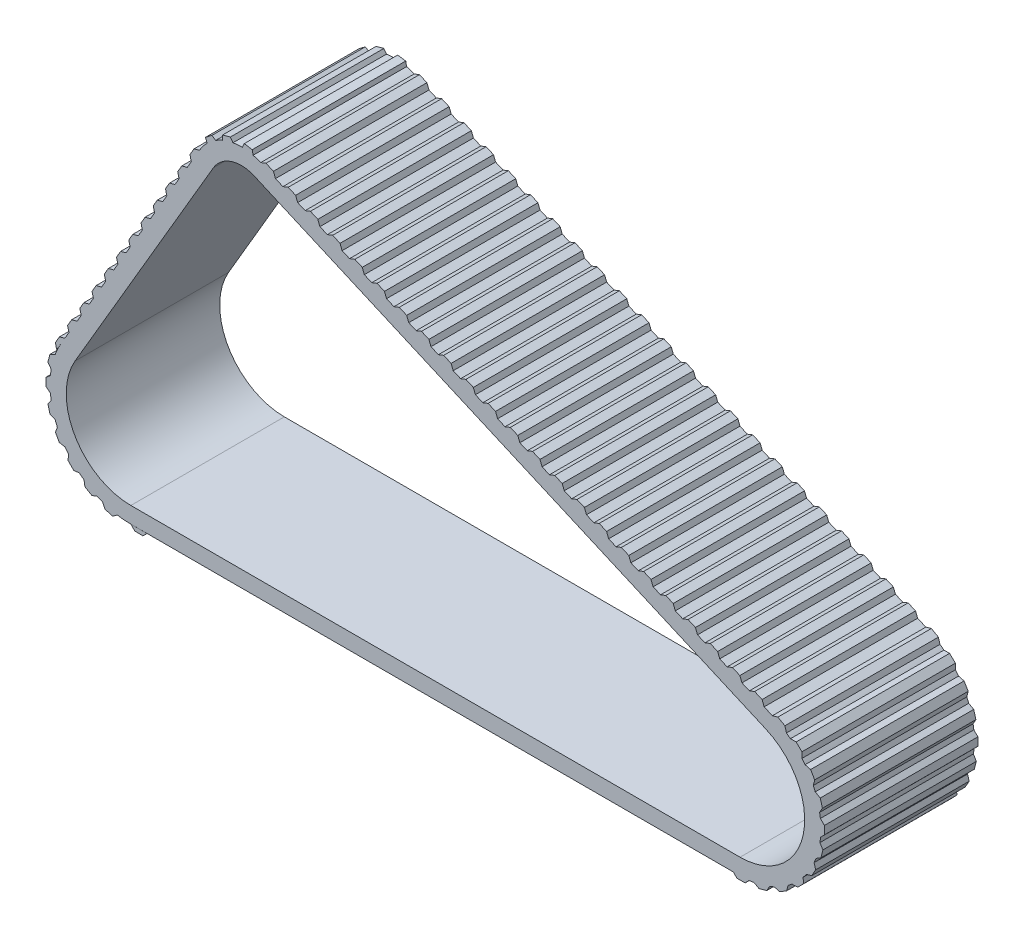
from build123d import *

# Parameters (mm, degrees)
EXTRUIR1_DEPTH         = 19
VACIADO1_T             = -2
CORTAR_EXTRUIR1_DEPTH  = 20
EXTRUIR2_DEPTH         = 19
MATRIZL1_COUNT         = 12
MATRIZL1_PITCH         = 3
EXTRUIR3_DEPTH         = 19
MATRIZL2_COUNT         = 23
MATRIZL2_PITCH         = 3
EXTRUIR4_DEPTH         = 19
MATRIZC2_COUNT         = 2
MATRIZC2_ANGLE         = 22
MATRIZC3_COUNT         = 2
MATRIZC3_ANGLE         = 24
EXTRUIR5_DEPTH         = 19
MATRIZC4_COUNT         = 11
MATRIZC4_ANGLE         = 150
EXTRUIR6_DEPTH         = 19
EXTRUIR7_DEPTH         = 19
MATRIZC5_COUNT         = 4
MATRIZC5_ANGLE         = 45
MATRIZC6_COPY_1_DEPTH  = 19
MATRIZC6_COPY_2_DEPTH  = 19
MATRIZC6_COPY_3_DEPTH  = 19
MATRIZC6_COPY_4_DEPTH  = 19
MATRIZC6_COPY_5_DEPTH  = 19
MATRIZC6_COPY_6_DEPTH  = 19
MATRIZC6_COPY_7_DEPTH  = 19
MATRIZC6_COPY_8_DEPTH  = 19
MATRIZC6_COPY_9_DEPTH  = 19
MATRIZC6_COPY_10_DEPTH = 19
MATRIZC6_COPY_11_DEPTH = 19
MATRIZC6_COPY_12_DEPTH = 19


with BuildPart() as part:
    # Croquis1 → Extruir1 (new body)
    with BuildSketch(Plane.XY):
        with BuildLine():
            Line((8.495183222, 34.324994884), (-8.631456282, 5.049550719))
            ThreePointArc((-8.631456282, 5.049550719), (-8.674546305, -4.975162953), (0, -10))
            Line((0, -10), (75.418767938, -10))
            ThreePointArc((75.418767938, -10), (85.208057182, -2.042012754), (79.416738635, 9.166036783))
            Line((79.416738635, 9.166036783), (16.072839409, 36.794886522))
            ThreePointArc((16.072839409, 36.794886522), (11.814670491, 36.999883795), (8.495183222, 34.324994884))
        make_face()
    extrude(amount=EXTRUIR1_DEPTH)

    # Vaciado1
    vaciado1_openings = [part.faces().sort_by_distance(p)[0] for p in [
        (33.687599882, 7.758573036, 19),
    ]]
    offset(amount=VACIADO1_T, openings=vaciado1_openings, kind=Kind.INTERSECTION)

    # Croquis2 → Cortar-Extruir1 (cut)
    with BuildSketch(Plane.XY.offset(2)):
        with BuildLine():
            Line((10.221474478, 33.31508474), (-6.905165025, 4.039640575))
            ThreePointArc((-6.905165025, 4.039640575), (-6.939637044, -3.980130362), (0, -8))
            Line((0, -8), (75.418767938, -8))
            ThreePointArc((75.418767938, -8), (83.250199333, -1.633610203), (78.617144496, 7.332829426))
            Line((78.617144496, 7.332829426), (15.27324527, 34.961679166))
            ThreePointArc((15.27324527, 34.961679166), (12.434465991, 35.098344014), (10.221474478, 33.31508474))
        make_face()
    extrude(amount=-CORTAR_EXTRUIR1_DEPTH, mode=Mode.SUBTRACT)

    # Croquis3 → Extruir2 (add)
    with BuildSketch(Plane.XY.offset(19)):
        Polygon((8.495183222, 34.324994884), (7.819852413, 34.140798524), (7.314897341, 33.277652895), (7.485273078, 32.598703627), align=None)
    extruir2 = extrude(amount=-EXTRUIR2_DEPTH)

    # MatrizL1: Extruir2 ×12
    with Locations(*[Vector(-0.504955072, -0.863145628, 0) * (i * MATRIZL1_PITCH) for i in range(1, MATRIZL1_COUNT)]):
        add(extruir2)

    # Croquis5 → Extruir3 (add)
    with BuildSketch(Plane.XY.offset(19)):
        Polygon((16.072839409, 36.794886522), (17.906046766, 35.995292383), (17.647643461, 36.653492757), (16.731039783, 37.053289827), align=None)
    extruir3 = extrude(amount=-EXTRUIR3_DEPTH)

    # MatrizL2: Extruir3 ×23
    with Locations(*[Vector(0.916603678, -0.39979707, 0) * (i * MATRIZL2_PITCH) for i in range(1, MATRIZL2_COUNT)]):
        add(extruir3)

    # Croquis8 → Extruir4 (add)
    with BuildSketch(Plane.XY.offset(19)):
        with BuildLine():
            Line((11.356671981, 37.399019639), (11.341082114, 36.823123733))
            ThreePointArc((11.341082114, 36.823123733), (11.980140179, 37.051187127), (12.640861941, 37.205637367))
            Line((12.640861941, 37.205637367), (12.321288909, 37.662675061))
            Line((12.321288909, 37.662675061), (11.356671981, 37.399019639))
        make_face()
    extruir4 = extrude(amount=-EXTRUIR4_DEPTH)

    # MatrizC2: Extruir4 ×2 about axis
    matrizc2_axis = Axis((13.674056991, 31.295264453, 0), (0, 0, 1))
    for i in range(1, MATRIZC2_COUNT):
        add(extruir4.rotate(matrizc2_axis, i * MATRIZC2_ANGLE / (MATRIZC2_COUNT - 1)))

    # MatrizC3: Extruir4 ×2 about axis
    matrizc3_axis = Axis((13.674056991, 31.295264453, 0), (0, 0, -1))
    for i in range(1, MATRIZC3_COUNT):
        add(extruir4.rotate(matrizc3_axis, i * MATRIZC3_ANGLE / (MATRIZC3_COUNT - 1)))

    # Croquis9 → Extruir5 (add)
    with BuildSketch(Plane.XY.offset(19)):
        Polygon((79.416738635, 9.166036783), (81.160797511, 8.187129923), (80.969509507, 8.867871357), (80.097480069, 9.357324787), align=None)
    extruir5 = extrude(amount=-EXTRUIR5_DEPTH)

    # MatrizC4: Extruir5 ×11 about axis
    matrizc4_axis = Axis((75.418767938, 0, 0), (0, 0, -1))
    for i in range(1, MATRIZC4_COUNT):
        add(extruir5.rotate(matrizc4_axis, i * MATRIZC4_ANGLE / (MATRIZC4_COUNT - 1)))

    # Croquis12 → Extruir7 (add)
    with BuildSketch(Plane(origin=(0, 0, 0), x_dir=(-1, 0, 0), z_dir=(0, 0, -1))):
        with BuildLine():
            Line((9.094839485, -4.157390377), (9.341040791, -4.81209121))
            Line((9.341040791, -4.81209121), (8.848638178, -5.682458756))
            Line((8.848638178, -5.682458756), (8.15129848, -5.792782845))
            ThreePointArc((8.15129848, -5.792782845), (8.66175189, -4.997404746), (9.094839485, -4.157390377))
        make_face()
    extruir7 = extrude(amount=-EXTRUIR7_DEPTH)

    # MatrizC5: Extruir7 ×4 about axis
    matrizc5_axis = Axis((0, 0, 0), (0, 0, -1))
    for i in range(1, MATRIZC5_COUNT):
        add(extruir7.rotate(matrizc5_axis, i * MATRIZC5_ANGLE / (MATRIZC5_COUNT - 1)))

    # MatrizC6 copy 1 sketch → MatrizC6 copy 1 (add)
    with BuildSketch(Plane(origin=(0, 0, 0), x_dir=(-1, 0, 0), z_dir=(0, 0, -1))):
        with BuildLine():
            Line((9.094839485, -4.157390377), (9.341040791, -4.81209121))
            Line((9.341040791, -4.81209121), (8.848638178, -5.682458756))
            Line((8.848638178, -5.682458756), (8.15129848, -5.792782845))
            ThreePointArc((8.15129848, -5.792782845), (8.66175189, -4.997404746), (9.094839485, -4.157390377))
        make_face()
    extrude(amount=-MATRIZC6_COPY_1_DEPTH)

    # MatrizC6 copy 2 sketch → MatrizC6 copy 2 (add)
    with BuildSketch(Plane(origin=(0, 0, 0), x_dir=(-0.965925826, -0.258819045, 0), z_dir=(0, 0, -1))):
        with BuildLine():
            Line((9.094839485, -4.157390377), (9.341040791, -4.81209121))
            Line((9.341040791, -4.81209121), (8.848638178, -5.682458756))
            Line((8.848638178, -5.682458756), (8.15129848, -5.792782845))
            ThreePointArc((8.15129848, -5.792782845), (8.66175189, -4.997404746), (9.094839485, -4.157390377))
        make_face()
    extrude(amount=-MATRIZC6_COPY_2_DEPTH)

    # MatrizC6 copy 3 sketch → MatrizC6 copy 3 (add)
    with BuildSketch(Plane(origin=(0, 0, 0), x_dir=(-0.866025404, -0.5, 0), z_dir=(0, 0, -1))):
        with BuildLine():
            Line((9.094839485, -4.157390377), (9.341040791, -4.81209121))
            Line((9.341040791, -4.81209121), (8.848638178, -5.682458756))
            Line((8.848638178, -5.682458756), (8.15129848, -5.792782845))
            ThreePointArc((8.15129848, -5.792782845), (8.66175189, -4.997404746), (9.094839485, -4.157390377))
        make_face()
    extrude(amount=-MATRIZC6_COPY_3_DEPTH)

    # MatrizC6 copy 4 sketch → MatrizC6 copy 4 (add)
    with BuildSketch(Plane(origin=(0, 0, 0), x_dir=(-0.965925826, 0.258819045, 0), z_dir=(0, 0, -1))):
        with BuildLine():
            Line((9.094839485, -4.157390377), (9.341040791, -4.81209121))
            Line((9.341040791, -4.81209121), (8.848638178, -5.682458756))
            Line((8.848638178, -5.682458756), (8.15129848, -5.792782845))
            ThreePointArc((8.15129848, -5.792782845), (8.66175189, -4.997404746), (9.094839485, -4.157390377))
        make_face()
    extrude(amount=-MATRIZC6_COPY_4_DEPTH)

    # MatrizC6 copy 5 sketch → MatrizC6 copy 5 (add)
    with BuildSketch(Plane(origin=(0, 0, 0), x_dir=(-1, 0, 0), z_dir=(0, 0, -1))):
        with BuildLine():
            Line((9.094839485, -4.157390377), (9.341040791, -4.81209121))
            Line((9.341040791, -4.81209121), (8.848638178, -5.682458756))
            Line((8.848638178, -5.682458756), (8.15129848, -5.792782845))
            ThreePointArc((8.15129848, -5.792782845), (8.66175189, -4.997404746), (9.094839485, -4.157390377))
        make_face()
    extrude(amount=-MATRIZC6_COPY_5_DEPTH)

    # MatrizC6 copy 6 sketch → MatrizC6 copy 6 (add)
    with BuildSketch(Plane(origin=(0, 0, 0), x_dir=(-0.965925826, -0.258819045, 0), z_dir=(0, 0, -1))):
        with BuildLine():
            Line((9.094839485, -4.157390377), (9.341040791, -4.81209121))
            Line((9.341040791, -4.81209121), (8.848638178, -5.682458756))
            Line((8.848638178, -5.682458756), (8.15129848, -5.792782845))
            ThreePointArc((8.15129848, -5.792782845), (8.66175189, -4.997404746), (9.094839485, -4.157390377))
        make_face()
    extrude(amount=-MATRIZC6_COPY_6_DEPTH)

    # MatrizC6 copy 7 sketch → MatrizC6 copy 7 (add)
    with BuildSketch(Plane(origin=(0, 0, 0), x_dir=(-0.866025404, 0.5, 0), z_dir=(0, 0, -1))):
        with BuildLine():
            Line((9.094839485, -4.157390377), (9.341040791, -4.81209121))
            Line((9.341040791, -4.81209121), (8.848638178, -5.682458756))
            Line((8.848638178, -5.682458756), (8.15129848, -5.792782845))
            ThreePointArc((8.15129848, -5.792782845), (8.66175189, -4.997404746), (9.094839485, -4.157390377))
        make_face()
    extrude(amount=-MATRIZC6_COPY_7_DEPTH)

    # MatrizC6 copy 8 sketch → MatrizC6 copy 8 (add)
    with BuildSketch(Plane(origin=(0, 0, 0), x_dir=(-0.965925826, 0.258819045, 0), z_dir=(0, 0, -1))):
        with BuildLine():
            Line((9.094839485, -4.157390377), (9.341040791, -4.81209121))
            Line((9.341040791, -4.81209121), (8.848638178, -5.682458756))
            Line((8.848638178, -5.682458756), (8.15129848, -5.792782845))
            ThreePointArc((8.15129848, -5.792782845), (8.66175189, -4.997404746), (9.094839485, -4.157390377))
        make_face()
    extrude(amount=-MATRIZC6_COPY_8_DEPTH)

    # MatrizC6 copy 9 sketch → MatrizC6 copy 9 (add)
    with BuildSketch(Plane(origin=(0, 0, 0), x_dir=(-1, 0, 0), z_dir=(0, 0, -1))):
        with BuildLine():
            Line((9.094839485, -4.157390377), (9.341040791, -4.81209121))
            Line((9.341040791, -4.81209121), (8.848638178, -5.682458756))
            Line((8.848638178, -5.682458756), (8.15129848, -5.792782845))
            ThreePointArc((8.15129848, -5.792782845), (8.66175189, -4.997404746), (9.094839485, -4.157390377))
        make_face()
    extrude(amount=-MATRIZC6_COPY_9_DEPTH)

    # MatrizC6 copy 10 sketch → MatrizC6 copy 10 (add)
    with BuildSketch(Plane(origin=(0, 0, 0), x_dir=(-0.965925826, -0.258819045, 0), z_dir=(0, 0, -1))):
        with BuildLine():
            Line((9.094839485, -4.157390377), (9.341040791, -4.81209121))
            Line((9.341040791, -4.81209121), (8.848638178, -5.682458756))
            Line((8.848638178, -5.682458756), (8.15129848, -5.792782845))
            ThreePointArc((8.15129848, -5.792782845), (8.66175189, -4.997404746), (9.094839485, -4.157390377))
        make_face()
    extrude(amount=-MATRIZC6_COPY_10_DEPTH)

    # MatrizC6 copy 11 sketch → MatrizC6 copy 11 (add)
    with BuildSketch(Plane(origin=(0, 0, 0), x_dir=(-0.866025404, -0.5, 0), z_dir=(0, 0, -1))):
        with BuildLine():
            Line((9.094839485, -4.157390377), (9.341040791, -4.81209121))
            Line((9.341040791, -4.81209121), (8.848638178, -5.682458756))
            Line((8.848638178, -5.682458756), (8.15129848, -5.792782845))
            ThreePointArc((8.15129848, -5.792782845), (8.66175189, -4.997404746), (9.094839485, -4.157390377))
        make_face()
    extrude(amount=-MATRIZC6_COPY_11_DEPTH)

    # MatrizC6 copy 12 sketch → MatrizC6 copy 12 (add)
    with BuildSketch(Plane(origin=(0, 0, 0), x_dir=(-0.707106781, -0.707106781, 0), z_dir=(0, 0, -1))):
        with BuildLine():
            Line((9.094839485, -4.157390377), (9.341040791, -4.81209121))
            Line((9.341040791, -4.81209121), (8.848638178, -5.682458756))
            Line((8.848638178, -5.682458756), (8.15129848, -5.792782845))
            ThreePointArc((8.15129848, -5.792782845), (8.66175189, -4.997404746), (9.094839485, -4.157390377))
        make_face()
    extrude(amount=-MATRIZC6_COPY_12_DEPTH)


with BuildPart() as body_2:
    # Croquis10 → Extruir6 (new body)
    with BuildSketch(Plane.XY.offset(19)):
        Polygon((0, -10), (2, -10.012130559), (1.5, -10.512130559), (0.5, -10.5), align=None)
    extrude(amount=-EXTRUIR6_DEPTH)


solid = Compound([part.part, body_2.part])
